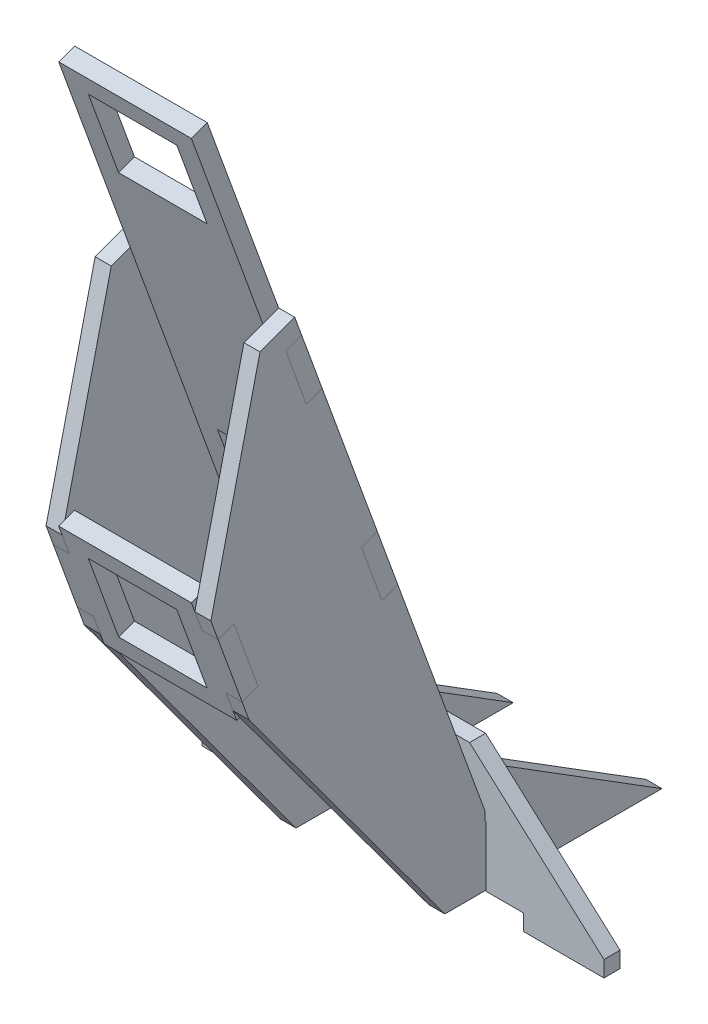
from build123d import *

# Parameters (mm, degrees)
BOSS_EXTRUDE1_DEPTH        = 28.575
BOSS_EXTRUDE1_DEPTH_BACK   = 13.335
BOSS_EXTRUDE1_2_DEPTH      = 28.575
BOSS_EXTRUDE1_2_DEPTH_BACK = 13.335
SKETCH4_W                  = 27.94
SKETCH4_H                  = 27.94
CUT_EXTRUDE1_DEPTH         = 63.223845758
SKETCH6_W                  = 25.4
SKETCH6_H                  = 5.08
BOSS_EXTRUDE2_DEPTH        = 5.08
SKETCH7_W                  = 5.334
SKETCH7_H                  = 19.05
CUT_EXTRUDE2_DEPTH         = 6.08
SKETCH8_W                  = 5.08
SKETCH8_H                  = 22.225
BOSS_EXTRUDE3_DEPTH        = 5.334
SKETCH10_W                 = 5.08
SKETCH10_H                 = 19.05
BOSS_EXTRUDE4_DEPTH        = 5.334
BOSS_EXTRUDE5_DEPTH        = 5.08


with BuildPart() as part:
    # Sketch3 → Boss-Extrude1 (new body, two sides)
    with BuildSketch(Plane(origin=(0, 0, 0), x_dir=(0, 0, -1), z_dir=(1, 0, 0))) as boss_extrude1_sk:
        Polygon((-6.44711232, -266.133060512), (-11.459432759, -267.957395957), (43.67427004, -419.435999447), (48.686590479, -417.611664002), align=None)
    extrude(amount=BOSS_EXTRUDE1_DEPTH)
    extrude(boss_extrude1_sk.sketch, amount=-BOSS_EXTRUDE1_DEPTH_BACK)


with BuildPart() as body_2:
    # Sketch3 → Boss-Extrude1 2 (new body, two sides)
    with BuildSketch(Plane(origin=(0, 0, 0), x_dir=(0, 0, -1), z_dir=(1, 0, 0))) as boss_extrude1_2_sk:
        Polygon((7.869577264, -432.467841864), (2.857256824, -434.292177309), (-11.459432759, -394.957395957), (-6.44711232, -393.133060512), align=None)
    extrude(amount=BOSS_EXTRUDE1_2_DEPTH)
    extrude(boss_extrude1_2_sk.sketch, amount=-BOSS_EXTRUDE1_2_DEPTH_BACK)


with BuildPart() as cut_extrude1_tool:
    # Sketch4 → Cut-Extrude1 (new body, through all)
    with BuildSketch(Plane(origin=(0, -33.203716147, 91.226460356), x_dir=(-1, 0, 0), z_dir=(0, 0.342020143, -0.939692621))):
        with Locations((-7.62, -268.807830831)):
            Rectangle(SKETCH4_W, SKETCH4_H)
        with Locations((-7.62, -388.148793671)):
            Rectangle(SKETCH4_W, SKETCH4_H)
    extrude(amount=-CUT_EXTRUDE1_DEPTH)


with BuildPart() as part_1:
    add(part.part)

    # Cut-Extrude1: cut by cut_extrude1_tool
    add(cut_extrude1_tool.part, mode=Mode.SUBTRACT)

    # Sketch10 → Boss-Extrude4 (add)
    with BuildSketch(Plane(origin=(0, -35.028051592, 96.238780795), x_dir=(1, 0, 0), z_dir=(0, -0.342020143, 0.939692621))):
        with Locations((-15.875, -399.553393671)):
            Rectangle(SKETCH10_W, SKETCH10_H)
        with Locations((31.115, -399.553393671)):
            Rectangle(SKETCH10_W, SKETCH10_H)
        with Locations((-15.875, -329.703393671)):
            Rectangle(SKETCH10_W, SKETCH10_H)
        with Locations((31.115, -329.703393671)):
            Rectangle(SKETCH10_W, SKETCH10_H)
    extrude(amount=-BOSS_EXTRUDE4_DEPTH)


with BuildPart() as body_2_1:
    add(body_2.part)

    # Cut-Extrude1: cut by cut_extrude1_tool
    add(cut_extrude1_tool.part, mode=Mode.SUBTRACT)

    # Sketch8 → Boss-Extrude3 (add)
    with BuildSketch(Plane(origin=(0, -49.884229453, 137.05579401), x_dir=(1, 0, 0), z_dir=(0, -0.342020143, 0.939692621))):
        with Locations((-15.875, -388.148793671)):
            Rectangle(SKETCH8_W, SKETCH8_H)
        with Locations((31.115, -388.148793671)):
            Rectangle(SKETCH8_W, SKETCH8_H)
    extrude(amount=-BOSS_EXTRUDE3_DEPTH)


with BuildPart() as body_3:
    # Sketch6 → Boss-Extrude2 (new body)
    with BuildSketch(Plane.XY.offset(-76.2)):
        Polygon((28.771446995, -476.924428702), (71.218223498, -515.024428702), (45.818223498, -515.024428702), (20.418223498, -515.024428702), (-4.981776502, -515.024428702), (-30.381776502, -515.024428702), (-55.781776502, -515.024428702), (-13.335, -476.924428702), align=None)
        with Locations((58.518223498, -517.564428702)):
            Rectangle(SKETCH6_W, SKETCH6_H)
        with Locations((7.718223498, -517.564428702)):
            Rectangle(SKETCH6_W, SKETCH6_H)
        with Locations((-43.081776502, -517.564428702)):
            Rectangle(SKETCH6_W, SKETCH6_H)
    extrude(amount=-BOSS_EXTRUDE2_DEPTH)

    # Sketch7 → Cut-Extrude2 (cut, through all)
    with BuildSketch(Plane.XY.offset(-76.2)):
        with Locations((31.242, -505.499428702)):
            Rectangle(SKETCH7_W, SKETCH7_H)
        with Locations((-16.002, -505.499428702)):
            Rectangle(SKETCH7_W, SKETCH7_H)
    extrude(amount=-CUT_EXTRUDE2_DEPTH, mode=Mode.SUBTRACT)


with BuildPart() as body_4:
    # Sketch11 → Boss-Extrude5 (new body)
    with BuildSketch(Plane.ZY.offset(13.335)):
        Polygon((-5.129803246, -332.102105227), (-11.096851388, -329.930277317), (-13.268679298, -335.897325459), (-19.784163028, -353.798469885), (-24.796483468, -351.97413444), (-42.171106748, -399.710519576), (-37.158786309, -401.534855021), (-43.67427004, -419.435999447), (-48.686590479, -417.611664002), (-76.2, -493.204135394), (-76.2, -495.974428702), (-81.28, -495.974428702), (-81.28, -483.274428702), (-132.08, -515.024428702), (-63.5, -515.024428702), (-1.671438786, -431.034169023), (0.500389125, -425.067120881), (-4.511931315, -423.242785437), (3.089466371, -402.35811694), (8.10178681, -404.182452384), (10.373518804, -397.940920028), align=None)
        Polygon((-11.096851388, -329.930277317), (-16.109171827, -328.105941872), (-18.280999737, -334.072990014), (-13.268679298, -335.897325459), align=None)
    extrude(amount=BOSS_EXTRUDE5_DEPTH)


with BuildPart() as body_5:
    # Mirror1: mirrored copy
    add(body_4.part.mirror(Plane.ZY.offset(-7.62)))


solid = Compound([part_1.part, body_2_1.part, body_3.part, body_4.part, body_5.part])
